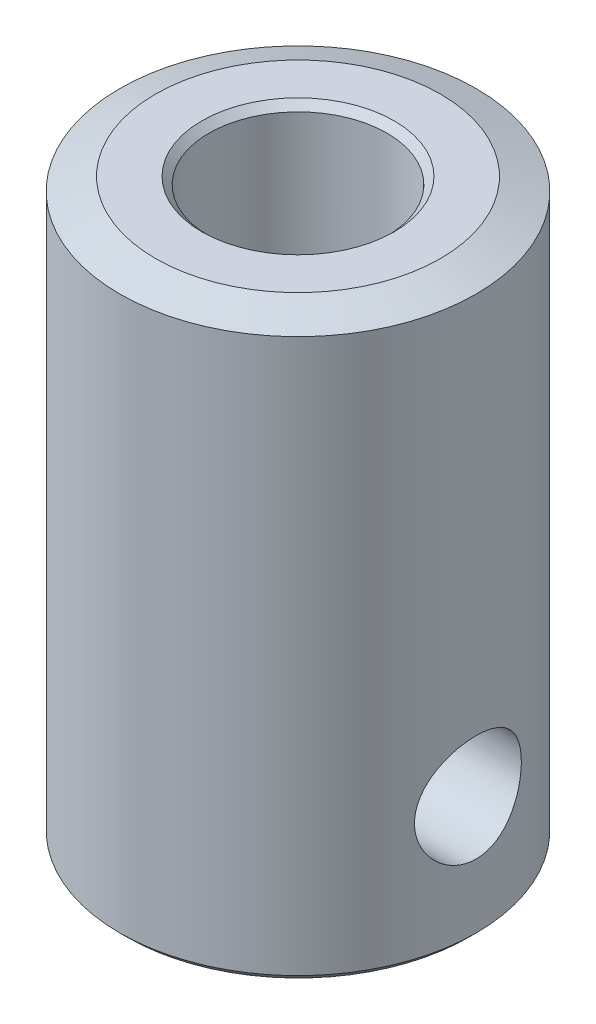
from build123d import *

# Parameters (mm, degrees)
SKETCH1_R           = 5
SKETCH1_R_2         = 2.5
BOSS_EXTRUDE1_DEPTH = 16.1
CHAMFER1_SIZE       = 0.2
CHAMFER2_SIZE       = 1
CHAMFER2_SIZE2      = 0.363970234
CUT_EXTRUDE1_REACH  = 21.601
SKETCH2_R           = 1.5
CIRPATTERN1_COUNT   = 2
CIRPATTERN1_ANGLE   = 90


with BuildPart() as part:
    # Sketch1 → Boss-Extrude1 (new body)
    with BuildSketch(Plane(origin=(0, 0, 0), x_dir=(1, 0, 0), z_dir=(0, 1, 0))):
        Circle(SKETCH1_R)
        Circle(SKETCH1_R_2, mode=Mode.SUBTRACT)
    extrude(amount=BOSS_EXTRUDE1_DEPTH)

    # Chamfer1
    chamfer1_edges = [part.edges().sort_by_distance(p)[0] for p in [
        (-2.5, 0, 0),
        (-5, 0, 0),
        (-2.5, 16.1, 0),
    ]]
    chamfer(chamfer1_edges, length=CHAMFER1_SIZE)

    # Chamfer2
    chamfer2_edges = [part.edges().sort_by_distance(p)[0] for p in [
        (-5, 16.1, 0),
    ]]
    chamfer2_side = [part.faces().sort_by_distance(p)[0] for p in [
        (-2.841421356, 16.1, 0),
    ]]
    chamfer(chamfer2_edges, length=CHAMFER2_SIZE, length2=CHAMFER2_SIZE2, reference=chamfer2_side[0])

    # Sketch2 → Cut-Extrude1 (cut, up to next)
    with BuildSketch(Plane(origin=(0, 0, -5), x_dir=(-1, 0, 0), z_dir=(0, 0, -1)), mode=Mode.PRIVATE) as cut_extrude1_sk1:
        with Locations((0, 3.5)):
            Circle(SKETCH2_R)
    cut_extrude1_tool1 = extrude(cut_extrude1_sk1.sketch, amount=-CUT_EXTRUDE1_REACH, mode=Mode.PRIVATE) & part.part
    cut_extrude1 = cut_extrude1_tool1.solids().sort_by_distance((0, 3.5, -5))[0]
    add(cut_extrude1, mode=Mode.SUBTRACT)

    # CirPattern1: Cut-Extrude1 ×2 about axis
    cirpattern1_axis = Axis((0, 15.9, 0), (0, -1, 0))
    for i in range(1, CIRPATTERN1_COUNT):
        add(cut_extrude1.rotate(cirpattern1_axis, i * CIRPATTERN1_ANGLE / (CIRPATTERN1_COUNT - 1)), mode=Mode.SUBTRACT)


solid = part.part
